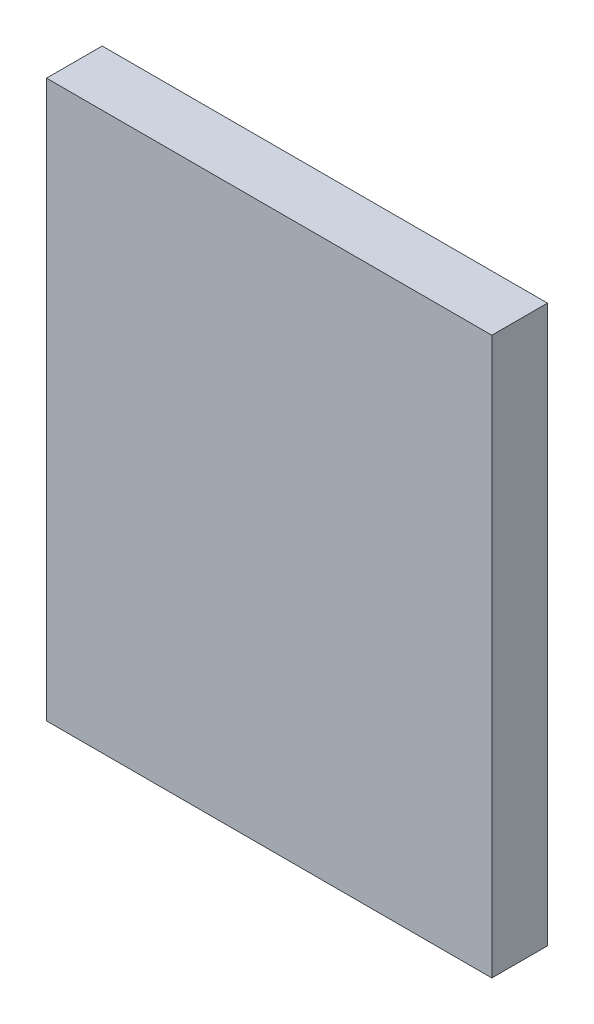
from build123d import *

# Parameters (mm, degrees)
SKETCH1_W           = 24
SKETCH1_H           = 30
BOSS_EXTRUDE1_DEPTH = 3


with BuildPart() as part:
    # Sketch1 → Boss-Extrude1 (new body)
    with BuildSketch(Plane.XY):
        Rectangle(SKETCH1_W, SKETCH1_H)
    extrude(amount=BOSS_EXTRUDE1_DEPTH)


solid = part.part
